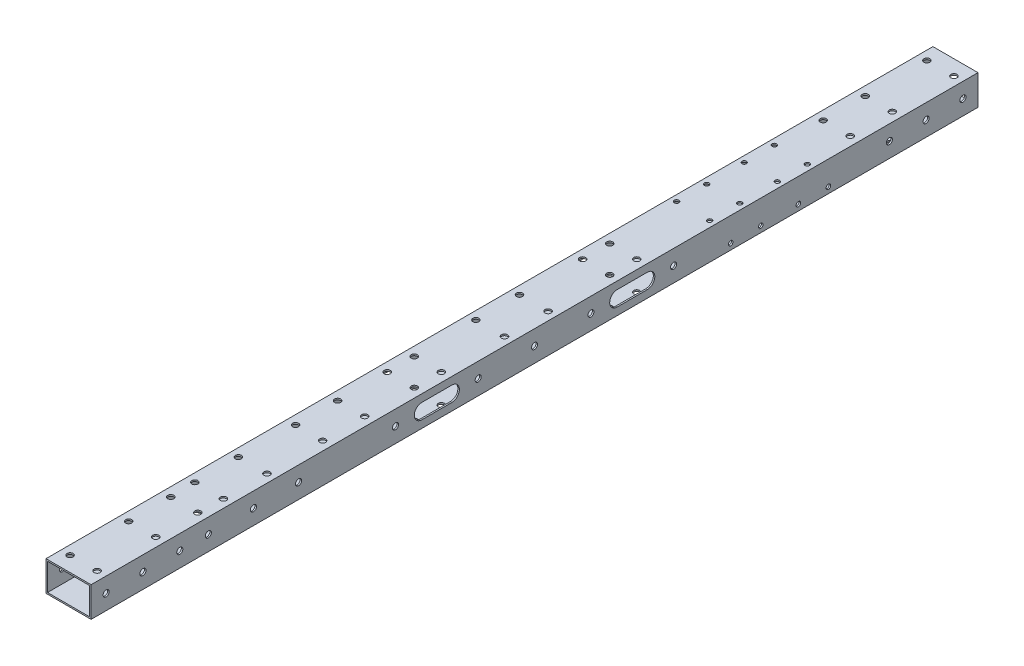
from build123d import *

# Parameters (mm, degrees)
SKETCH_1_W                = 30
SKETCH_1_H                = 20
SKETCH_1_W_2              = 28
SKETCH_1_H_2              = 18
EXTRUDE_1_DEPTH           = 295
SKETCH_5_R                = 2.025
CUT_EXTRUDE_4_DEPTH       = 5
SKETCH_7_R                = 3.8
CUT_EXTRUDE_5_DEPTH       = 5
SKETCH_11_R               = 2.025
CUT_EXTRUDE_9_DEPTH       = 113
SKETCH_18_R               = 2.025
CUT_EXTRUDE_16_DEPTH      = 90
SKETCH_21_R               = 2.025
CUT_EXTRUDE_19_DEPTH      = 126
SKETCH_22_R               = 2.025
CUT_EXTRUDE_20_DEPTH      = 10
SKETCH_26_R               = 1.525
CUT_EXTRUDE_24_DEPTH      = 10
SKETCH_27_R               = 1.525
CUT_EXTRUDE_25_DEPTH      = 100
CUT_EXTRUDE_26_DEPTH      = 100
SKETCH_31_R               = 2.025
CUT_EXTRUDE_29_DEPTH      = 50
SKETCH_32_R               = 3.75
CUT_EXTRUDE_30_DEPTH      = 10
SKETCH_36_R               = 2.025
CUT_EXTRUDE_33_DEPTH      = 37
SKETCH_37_R               = 3.8
CUT_EXTRUDE_34_DEPTH      = 10
SKETCH_38_R               = 2.5
EXTRUDE_2_DEPTH           = 1
SKETCH_39_R               = 6
EXTRUDE_3_DEPTH           = 1
SKETCH_40_R               = 2.025
EXTRUDE_4_DEPTH           = 1
SKETCH_41_R               = 2.025
EXTRUDE_5_DEPTH           = 1
CUT_EXTRUDE_36_DEPTH      = 30
SKETCH_43_R               = 2.5
EXTRUDE_6_DEPTH           = 1
SKETCH_44_R               = 2.5
EXTRUDE_7_DEPTH           = 1
SKETCH_45_R               = 2.025
CUT_EXTRUDE_37_DEPTH      = 30
SKETCH_47_W               = 25.744975694
SKETCH_47_H               = 50
EXTRUDE_8_DEPTH           = 1
SKETCH_46_R               = 2.025
CUT_EXTRUDE_38_DEPTH      = 1
SKETCH_48_W               = 30
SKETCH_48_H               = 40.498522019
EXTRUDE_9_DEPTH           = 1
SKETCH_50_R               = 3.8
CUT_EXTRUDE_40_DEPTH      = 1
SKETCH_51_R               = 4.5
EXTRUDE_10_DEPTH          = 1
SKETCH_52_R               = 2.5
EXTRUDE_11_DEPTH          = 1
SKETCH_53_R               = 2.5
EXTRUDE_12_DEPTH          = 1
SKETCH_54_R               = 2.5
EXTRUDE_13_DEPTH          = 1
SKETCH_55_R               = 2
EXTRUDE_14_DEPTH          = 1
SKETCH_56_R               = 2
EXTRUDE_15_DEPTH          = 1
SKETCH_57_R               = 2
EXTRUDE_16_DEPTH          = 1
SKETCH_58_R               = 2.025
CUT_EXTRUDE_41_DEPTH      = 1
CUT_EXTRUDE_41_DEPTH_BACK = 21
SKETCH_59_R               = 3.8
CUT_EXTRUDE_42_DEPTH      = 3
SKETCH_61_R               = 1.525
CUT_EXTRUDE_43_DEPTH      = 1
CUT_EXTRUDE_43_DEPTH_BACK = 21
SKETCH_62_R               = 2.5
EXTRUDE_17_DEPTH          = 1
SKETCH_63_R               = 2.5
EXTRUDE_18_DEPTH          = 1
SKETCH_64_R               = 1.525
CUT_EXTRUDE_44_DEPTH      = 1
CUT_EXTRUDE_44_DEPTH_BACK = 31
SKETCH_65_R               = 4
EXTRUDE_19_DEPTH          = 1
SKETCH_66_R               = 4
EXTRUDE_20_DEPTH          = 1
SKETCH_67_R               = 2.5
EXTRUDE_21_DEPTH          = 1
SKETCH_68_R               = 2.5
EXTRUDE_22_DEPTH          = 1


with BuildPart() as part:
    # Sketch 1 → Extrude 1 (new body, symmetric)
    with BuildSketch(Plane.XY):
        Rectangle(SKETCH_1_W, SKETCH_1_H)
        Rectangle(SKETCH_1_W_2, SKETCH_1_H_2, mode=Mode.SUBTRACT)
    extrude(amount=EXTRUDE_1_DEPTH, both=True)

    # Sketch 5 → Cut-Extrude 4 (cut, symmetric)
    with BuildSketch(Plane.XZ.offset(-9)):
        with Locations((-9.5, -172.5)):
            Circle(SKETCH_5_R)
        with Locations((9.5, -172.5)):
            Circle(SKETCH_5_R)
        with Locations((-9.5, -201.5)):
            Circle(SKETCH_5_R)
        with Locations((9.5, -201.5)):
            Circle(SKETCH_5_R)
        with Locations((-9.5, -14.5)):
            Circle(SKETCH_5_R)
        with Locations((9.5, -14.5)):
            Circle(SKETCH_5_R)
        with Locations((-9.5, 14.5)):
            Circle(SKETCH_5_R)
        with Locations((9.5, 14.5)):
            Circle(SKETCH_5_R)
        with Locations((-9.5, 172.5)):
            Circle(SKETCH_5_R)
        with Locations((-9.5, 201.5)):
            Circle(SKETCH_5_R)
        with Locations((9.5, 201.5)):
            Circle(SKETCH_5_R)
        with Locations((9.5, 172.5)):
            Circle(SKETCH_5_R)
    extrude(amount=CUT_EXTRUDE_4_DEPTH, both=True, mode=Mode.SUBTRACT)

    # Sketch 7 → Cut-Extrude 5 (cut, symmetric)
    with BuildSketch(Plane(origin=(0, -9, 0), x_dir=(1, 0, 0), z_dir=(0, 1, 0))):
        with Locations((-9.5, 201.5)):
            Circle(SKETCH_7_R)
        with Locations((9.5, 201.5)):
            Circle(SKETCH_7_R)
        with Locations((-9.5, 172.5)):
            Circle(SKETCH_7_R)
        with Locations((9.5, 172.5)):
            Circle(SKETCH_7_R)
        with Locations((-9.5, 14.5)):
            Circle(SKETCH_7_R)
        with Locations((9.5, 14.5)):
            Circle(SKETCH_7_R)
        with Locations((-9.5, -14.5)):
            Circle(SKETCH_7_R)
        with Locations((9.5, -14.5)):
            Circle(SKETCH_7_R)
        with Locations((-9.5, -172.5)):
            Circle(SKETCH_7_R)
        with Locations((9.5, -172.5)):
            Circle(SKETCH_7_R)
        with Locations((-9.5, -201.5)):
            Circle(SKETCH_7_R)
        with Locations((9.5, -201.5)):
            Circle(SKETCH_7_R)
    extrude(amount=CUT_EXTRUDE_5_DEPTH, both=True, mode=Mode.SUBTRACT)

    # Sketch 11 → Cut-Extrude 9 (cut)
    with BuildSketch(Plane(origin=(15, 0, 0), x_dir=(0, 0, -1), z_dir=(1, 0, 0))):
        with Locations((217, 0)):
            Circle(SKETCH_11_R)
        with Locations((187, 0)):
            Circle(SKETCH_11_R)
        with Locations((157, 0)):
            Circle(SKETCH_11_R)
        with Locations((30, 0)):
            Circle(SKETCH_11_R)
        Circle(SKETCH_11_R)
        with Locations((-30, 0)):
            Circle(SKETCH_11_R)
        with Locations((-157, 0)):
            Circle(SKETCH_11_R)
        with Locations((-187, 0)):
            Circle(SKETCH_11_R)
        with Locations((-217, 0)):
            Circle(SKETCH_11_R)
        with Locations((-236, 0)):
            Circle(SKETCH_11_R)
        with Locations((-260.5, 0)):
            Circle(SKETCH_11_R)
        with Locations((-285, 0)):
            Circle(SKETCH_11_R)
    cut_extrude_9 = extrude(amount=-CUT_EXTRUDE_9_DEPTH, mode=Mode.SUBTRACT)

    # Sketch 18 → Cut-Extrude 16 (cut)
    with BuildSketch(Plane.XZ.offset(10)):
        with Locations((-9, 74)):
            Circle(SKETCH_18_R)
        with Locations((9, 74)):
            Circle(SKETCH_18_R)
        with Locations((-9, 56)):
            Circle(SKETCH_18_R)
        with Locations((9, 56)):
            Circle(SKETCH_18_R)
    cut_extrude_16 = extrude(amount=-CUT_EXTRUDE_16_DEPTH, mode=Mode.SUBTRACT)

    # Mirror 1: Cut-Extrude 16 across plane
    add(cut_extrude_16.mirror(Plane.XY), mode=Mode.SUBTRACT)

    # Sketch 21 → Cut-Extrude 19 (cut)
    with BuildSketch(Plane(origin=(15, 0, 0), x_dir=(0, 0, -1), z_dir=(1, 0, 0))):
        with Locations((-46, 0)):
            Circle(SKETCH_21_R)
        with Locations((-84, 0)):
            Circle(SKETCH_21_R)
    extrude(amount=-CUT_EXTRUDE_19_DEPTH, mode=Mode.SUBTRACT)

    # Sketch 22 → Cut-Extrude 20 (cut)
    with BuildSketch(Plane(origin=(0, 10, 0), x_dir=(1, 0, 0), z_dir=(0, 1, 0))):
        with Locations((-9, 285)):
            Circle(SKETCH_22_R)
        with Locations((9, 285)):
            Circle(SKETCH_22_R)
    cut_extrude_20 = extrude(amount=-CUT_EXTRUDE_20_DEPTH, mode=Mode.SUBTRACT)

    # Sketch 26 → Cut-Extrude 24 (cut)
    with BuildSketch(Plane.XZ.offset(10)):
        with Locations((-11, 124)):
            Circle(SKETCH_26_R)
        with Locations((-11, 144)):
            Circle(SKETCH_26_R)
        with Locations((11, 144)):
            Circle(SKETCH_26_R)
        with Locations((11, 124)):
            Circle(SKETCH_26_R)
    extrude(amount=-CUT_EXTRUDE_24_DEPTH, mode=Mode.SUBTRACT)

    # Sketch 27 → Cut-Extrude 25 (cut)
    with BuildSketch(Plane.ZY.offset(15)):
        with Locations((134, -6)):
            Circle(SKETCH_27_R)
        with Locations((114, -6)):
            Circle(SKETCH_27_R)
    extrude(amount=-CUT_EXTRUDE_25_DEPTH, mode=Mode.SUBTRACT)

    # Sketch 28 → Cut-Extrude 26 (cut)
    with BuildSketch(Plane(origin=(15, 0, 0), x_dir=(0, 0, -1), z_dir=(1, 0, 0))):
        with BuildLine():
            Line((-71, 5), (-59, 5))
            ThreePointArc((-59, 5), (-54, 0), (-59, -5))
            Line((-59, -5), (-71, -5))
            ThreePointArc((-71, -5), (-76, 0), (-71, 5))
        make_face()
    cut_extrude_26 = extrude(amount=-CUT_EXTRUDE_26_DEPTH, mode=Mode.SUBTRACT)

    # Mirror 2: Cut-Extrude 26 across plane
    add(cut_extrude_26.mirror(Plane.XY), mode=Mode.SUBTRACT)

    # Sketch 31 → Cut-Extrude 29 (cut)
    with BuildSketch(Plane(origin=(0, 10, 0), x_dir=(1, 0, 0), z_dir=(0, 1, 0))):
        with Locations((0, 72)):
            Circle(SKETCH_31_R)
        with Locations((0, 132)):
            Circle(SKETCH_31_R)
    extrude(amount=-CUT_EXTRUDE_29_DEPTH, mode=Mode.SUBTRACT)

    # Sketch 32 → Cut-Extrude 30 (cut)
    with BuildSketch(Plane.ZY.offset(15)):
        with Locations((46, 0)):
            Circle(SKETCH_32_R)
        with Locations((84, 0)):
            Circle(SKETCH_32_R)
    extrude(amount=-CUT_EXTRUDE_30_DEPTH, mode=Mode.SUBTRACT)

    # Sketch 36 → Cut-Extrude 33 (cut)
    with BuildSketch(Plane(origin=(0, 10, 0), x_dir=(1, 0, 0), z_dir=(0, 1, 0))):
        with Locations((-9, 244)):
            Circle(SKETCH_36_R)
        with Locations((-9, 216)):
            Circle(SKETCH_36_R)
        with Locations((9, 216)):
            Circle(SKETCH_36_R)
        with Locations((9, 244)):
            Circle(SKETCH_36_R)
    cut_extrude_33 = extrude(amount=-CUT_EXTRUDE_33_DEPTH, mode=Mode.SUBTRACT)

    # Sketch 37 → Cut-Extrude 34 (cut)
    with BuildSketch(Plane.XZ.offset(10)):
        with Locations((-9, -216)):
            Circle(SKETCH_37_R)
        with Locations((9, -216)):
            Circle(SKETCH_37_R)
        with Locations((-9, -244)):
            Circle(SKETCH_37_R)
        with Locations((9, -244)):
            Circle(SKETCH_37_R)
    cut_extrude_34 = extrude(amount=-CUT_EXTRUDE_34_DEPTH, mode=Mode.SUBTRACT)

    # Mirror 3: Cut-Extrude 33, Cut-Extrude 34 across plane
    add(cut_extrude_33.mirror(Plane.XY), mode=Mode.SUBTRACT)
    add(cut_extrude_34.mirror(Plane.XY), mode=Mode.SUBTRACT)

    # Sketch 38 → Extrude 2 (add)
    with BuildSketch(Plane(origin=(15, 0, 0), x_dir=(0, 0, -1), z_dir=(1, 0, 0))):
        with Locations((-84, 0)):
            Circle(SKETCH_38_R)
        with Locations((-46, 0)):
            Circle(SKETCH_38_R)
    extrude(amount=-EXTRUDE_2_DEPTH)

    # Sketch 39 → Extrude 3 (add)
    with BuildSketch(Plane.ZY.offset(15)):
        with Locations((84, 0)):
            Circle(SKETCH_39_R)
        with Locations((46, 0)):
            Circle(SKETCH_39_R)
    extrude(amount=-EXTRUDE_3_DEPTH)

    # Sketch 40 → Extrude 4 (add)
    with BuildSketch(Plane(origin=(0, 10, 0), x_dir=(1, 0, 0), z_dir=(0, 1, 0))):
        with Locations((0, 72)):
            Circle(SKETCH_40_R)
    extrude(amount=-EXTRUDE_4_DEPTH)

    # Sketch 41 → Extrude 5 (add)
    with BuildSketch(Plane.XZ.offset(10)):
        with Locations((0, -72)):
            Circle(SKETCH_41_R)
    extrude(amount=-EXTRUDE_5_DEPTH)

    # Sketch 42 → Cut-Extrude 36 (cut)
    with BuildSketch(Plane.ZY.offset(15)):
        with BuildLine():
            Line((-75, 5), (-55, 5))
            ThreePointArc((-55, 5), (-50, 0), (-55, -5))
            Line((-55, -5), (-75, -5))
            ThreePointArc((-75, -5), (-80, 0), (-75, 5))
        make_face()
        with BuildLine():
            Line((75, 5), (55, 5))
            ThreePointArc((55, 5), (50, 0), (55, -5))
            Line((55, -5), (75, -5))
            ThreePointArc((75, -5), (80, 0), (75, 5))
        make_face()
    extrude(amount=-CUT_EXTRUDE_36_DEPTH, mode=Mode.SUBTRACT)

    # Sketch 43 → Extrude 6 (add)
    with BuildSketch(Plane.ZY.offset(15)):
        with Locations((-30, 0)):
            Circle(SKETCH_43_R)
        Circle(SKETCH_43_R)
        with Locations((30, 0)):
            Circle(SKETCH_43_R)
    extrude(amount=-EXTRUDE_6_DEPTH)

    # Sketch 44 → Extrude 7 (add)
    with BuildSketch(Plane(origin=(15, 0, 0), x_dir=(0, 0, -1), z_dir=(1, 0, 0))):
        with Locations((-30, 0)):
            Circle(SKETCH_44_R)
        Circle(SKETCH_44_R)
        with Locations((30, 0)):
            Circle(SKETCH_44_R)
    extrude(amount=-EXTRUDE_7_DEPTH)

    # Sketch 45 → Cut-Extrude 37 (cut)
    with BuildSketch(Plane.ZY.offset(15)):
        with Locations((-92.5, 0)):
            Circle(SKETCH_45_R)
        with Locations((-37.5, 0)):
            Circle(SKETCH_45_R)
        with Locations((37.5, 0)):
            Circle(SKETCH_45_R)
        with Locations((92.5, 0)):
            Circle(SKETCH_45_R)
    extrude(amount=-CUT_EXTRUDE_37_DEPTH, mode=Mode.SUBTRACT)

    # Sketch 47 → Extrude 8 (add)
    with BuildSketch(Plane(origin=(0, 10, 0), x_dir=(1, 0, 0), z_dir=(0, 1, 0))):
        with Locations((0, -235.182222901)):
            Rectangle(SKETCH_47_W, SKETCH_47_H)
    extrude(amount=-EXTRUDE_8_DEPTH)

    # Sketch 46 → Cut-Extrude 38 (cut)
    with BuildSketch(Plane(origin=(0, 10, 0), x_dir=(1, 0, 0), z_dir=(0, 1, 0))):
        with Locations((9, -218)):
            Circle(SKETCH_46_R)
        with Locations((9, -246)):
            Circle(SKETCH_46_R)
        with Locations((-9, -246)):
            Circle(SKETCH_46_R)
        with Locations((-9, -218)):
            Circle(SKETCH_46_R)
    extrude(amount=-CUT_EXTRUDE_38_DEPTH, mode=Mode.SUBTRACT)

    # Sketch 48 → Extrude 9 (add)
    with BuildSketch(Plane.XZ.offset(10)):
        with Locations((0, 228.709249114)):
            Rectangle(SKETCH_48_W, SKETCH_48_H)
    extrude(amount=-EXTRUDE_9_DEPTH)

    # Sketch 50 → Cut-Extrude 40 (cut)
    with BuildSketch(Plane(origin=(0, -9, 0), x_dir=(1, 0, 0), z_dir=(0, 1, 0))):
        with Locations((-9, -246)):
            Circle(SKETCH_50_R)
        with Locations((-9, -218)):
            Circle(SKETCH_50_R)
        with Locations((9, -218)):
            Circle(SKETCH_50_R)
        with Locations((9, -246)):
            Circle(SKETCH_50_R)
    extrude(amount=-CUT_EXTRUDE_40_DEPTH, mode=Mode.SUBTRACT)

    # Sketch 51 → Extrude 10 (add)
    with BuildSketch(Plane.XZ.offset(10)):
        with Locations((9.5, -201.5)):
            Circle(SKETCH_51_R)
        with Locations((-9.5, -201.5)):
            Circle(SKETCH_51_R)
        with Locations((-9.5, -172.5)):
            Circle(SKETCH_51_R)
        with Locations((9.5, -172.5)):
            Circle(SKETCH_51_R)
    extrude(amount=-EXTRUDE_10_DEPTH)

    # Sketch 52 → Extrude 11 (add)
    with BuildSketch(Plane(origin=(0, 10, 0), x_dir=(1, 0, 0), z_dir=(0, 1, 0))):
        with Locations((-9.5, 172.5)):
            Circle(SKETCH_52_R)
        with Locations((-9.5, 201.5)):
            Circle(SKETCH_52_R)
        with Locations((9.5, 201.5)):
            Circle(SKETCH_52_R)
        with Locations((9.5, 172.5)):
            Circle(SKETCH_52_R)
    extrude(amount=-EXTRUDE_11_DEPTH)

    # Sketch 53 → Extrude 12 (add)
    with BuildSketch(Plane.XZ.offset(10)):
        with Locations((0, -132)):
            Circle(SKETCH_53_R)
    extrude(amount=-EXTRUDE_12_DEPTH)

    # Sketch 54 → Extrude 13 (add)
    with BuildSketch(Plane(origin=(0, 10, 0), x_dir=(1, 0, 0), z_dir=(0, 1, 0))):
        with Locations((0, 132)):
            Circle(SKETCH_54_R)
    extrude(amount=-EXTRUDE_13_DEPTH)

    # Sketch 55 → Extrude 14 (add)
    with BuildSketch(Plane.XZ.offset(10)):
        with Locations((11, 124)):
            Circle(SKETCH_55_R)
        with Locations((11, 144)):
            Circle(SKETCH_55_R)
        with Locations((-11, 144)):
            Circle(SKETCH_55_R)
        with Locations((-11, 124)):
            Circle(SKETCH_55_R)
    extrude(amount=-EXTRUDE_14_DEPTH)

    # Sketch 56 → Extrude 15 (add)
    with BuildSketch(Plane(origin=(15, 0, 0), x_dir=(0, 0, -1), z_dir=(1, 0, 0))):
        with Locations((-134, -6)):
            Circle(SKETCH_56_R)
        with Locations((-114, -6)):
            Circle(SKETCH_56_R)
    extrude(amount=-EXTRUDE_15_DEPTH)

    # Sketch 57 → Extrude 16 (add)
    with BuildSketch(Plane.ZY.offset(15)):
        with Locations((114, -6)):
            Circle(SKETCH_57_R)
        with Locations((134, -6)):
            Circle(SKETCH_57_R)
    extrude(amount=-EXTRUDE_16_DEPTH)

    # Sketch 58 → Cut-Extrude 41 (cut, two sides)
    with BuildSketch(Plane.XZ.offset(10)) as cut_extrude_41_sk:
        with Locations((-9, 135)):
            Circle(SKETCH_58_R)
        with Locations((-9, 107)):
            Circle(SKETCH_58_R)
        with Locations((9, 107)):
            Circle(SKETCH_58_R)
        with Locations((9, 135)):
            Circle(SKETCH_58_R)
    extrude(amount=CUT_EXTRUDE_41_DEPTH, mode=Mode.SUBTRACT)
    extrude(cut_extrude_41_sk.sketch, amount=-CUT_EXTRUDE_41_DEPTH_BACK, mode=Mode.SUBTRACT)

    # Sketch 59 → Cut-Extrude 42 (cut)
    with BuildSketch(Plane.XZ.offset(10)):
        with Locations((-9, 135)):
            Circle(SKETCH_59_R)
        with Locations((-9, 107)):
            Circle(SKETCH_59_R)
        with Locations((9, 107)):
            Circle(SKETCH_59_R)
        with Locations((9, 135)):
            Circle(SKETCH_59_R)
    extrude(amount=-CUT_EXTRUDE_42_DEPTH, mode=Mode.SUBTRACT)

    # Sketch 61 → Cut-Extrude 43 (cut, two sides)
    with BuildSketch(Plane.XZ.offset(10)) as cut_extrude_43_sk:
        with Locations((11, -185.5)):
            Circle(SKETCH_61_R)
        with Locations((11, -165.5)):
            Circle(SKETCH_61_R)
        with Locations((11, -120.5)):
            Circle(SKETCH_61_R)
        with Locations((11, -140.5)):
            Circle(SKETCH_61_R)
        with Locations((-11, -140.5)):
            Circle(SKETCH_61_R)
        with Locations((-11, -120.5)):
            Circle(SKETCH_61_R)
        with Locations((-11, -165.5)):
            Circle(SKETCH_61_R)
        with Locations((-11, -185.5)):
            Circle(SKETCH_61_R)
    extrude(amount=CUT_EXTRUDE_43_DEPTH, mode=Mode.SUBTRACT)
    extrude(cut_extrude_43_sk.sketch, amount=-CUT_EXTRUDE_43_DEPTH_BACK, mode=Mode.SUBTRACT)

    # Sketch 62 → Extrude 17 (add)
    with BuildSketch(Plane.ZY.offset(15)):
        with Locations((-217, 0)):
            Circle(SKETCH_62_R)
        with Locations((-187, 0)):
            Circle(SKETCH_62_R)
        with Locations((-157, 0)):
            Circle(SKETCH_62_R)
    extrude(amount=-EXTRUDE_17_DEPTH)

    # Sketch 63 → Extrude 18 (add)
    with BuildSketch(Plane(origin=(15, 0, 0), x_dir=(0, 0, -1), z_dir=(1, 0, 0))):
        with Locations((157, 0)):
            Circle(SKETCH_63_R)
        with Locations((187, 0)):
            Circle(SKETCH_63_R)
        with Locations((217, 0)):
            Circle(SKETCH_63_R)
    extrude(amount=-EXTRUDE_18_DEPTH)

    # Sketch 64 → Cut-Extrude 44 (cut, two sides)
    with BuildSketch(Plane(origin=(15, 0, 0), x_dir=(0, 0, -1), z_dir=(1, 0, 0))) as cut_extrude_44_sk:
        with Locations((130.5, -6)):
            Circle(SKETCH_64_R)
        with Locations((150.5, -6)):
            Circle(SKETCH_64_R)
        with Locations((175.5, -6)):
            Circle(SKETCH_64_R)
        with Locations((195.5, -6)):
            Circle(SKETCH_64_R)
    extrude(amount=CUT_EXTRUDE_44_DEPTH, mode=Mode.SUBTRACT)
    extrude(cut_extrude_44_sk.sketch, amount=-CUT_EXTRUDE_44_DEPTH_BACK, mode=Mode.SUBTRACT)

    # Mirror 4: Cut-Extrude 9 across plane
    add(cut_extrude_9.mirror(Plane.XY), mode=Mode.SUBTRACT)

    # Sketch 65 → Extrude 19 (add)
    with BuildSketch(Plane.ZY.offset(15)):
        with Locations((-217, 0)):
            Circle(SKETCH_65_R)
        with Locations((-187, 0)):
            Circle(SKETCH_65_R)
        with Locations((-157, 0)):
            Circle(SKETCH_65_R)
    extrude(amount=-EXTRUDE_19_DEPTH)

    # Sketch 66 → Extrude 20 (add)
    with BuildSketch(Plane(origin=(15, 0, 0), x_dir=(0, 0, -1), z_dir=(1, 0, 0))):
        with Locations((157, 0)):
            Circle(SKETCH_66_R)
        with Locations((187, 0)):
            Circle(SKETCH_66_R)
        with Locations((217, 0)):
            Circle(SKETCH_66_R)
    extrude(amount=-EXTRUDE_20_DEPTH)

    # Mirror 5: Cut-Extrude 20 across plane
    add(cut_extrude_20.mirror(Plane.XY), mode=Mode.SUBTRACT)

    # Sketch 67 → Extrude 21 (add)
    with BuildSketch(Plane.ZY.offset(15)):
        with Locations((-30, 0)):
            Circle(SKETCH_67_R)
        with Locations((30, 0)):
            Circle(SKETCH_67_R)
    extrude(amount=-EXTRUDE_21_DEPTH)

    # Sketch 68 → Extrude 22 (add)
    with BuildSketch(Plane(origin=(15, 0, 0), x_dir=(0, 0, -1), z_dir=(1, 0, 0))):
        with Locations((-30, 0)):
            Circle(SKETCH_68_R)
        with Locations((30, 0)):
            Circle(SKETCH_68_R)
    extrude(amount=-EXTRUDE_22_DEPTH)


solid = part.part
